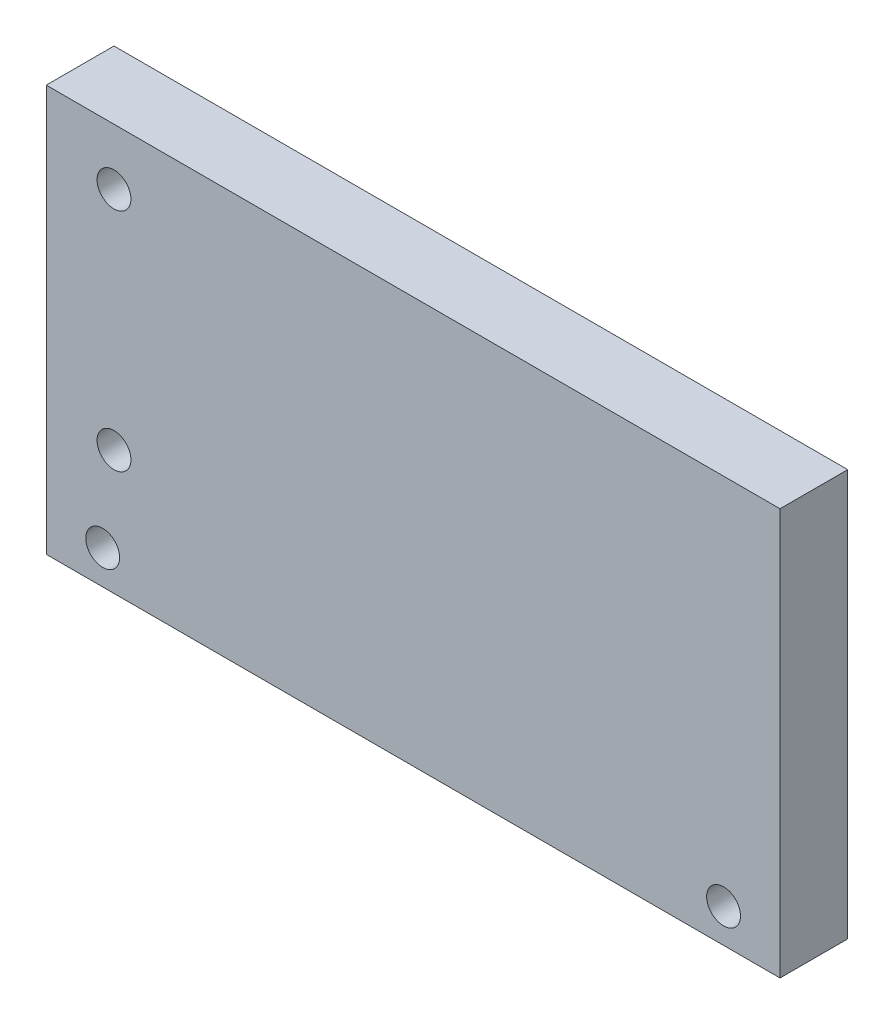
from build123d import *

# Parameters (mm, degrees)
ESQUISSE1_W             = 65
ESQUISSE1_H             = 36
ESQUISSE1_R             = 1.5
BOSS_EXTRU_1_DEPTH      = 6
ESQUISSE3_R             = 1.5
ENL_V_MAT_EXTRU_1_DEPTH = 10


with BuildPart() as part:
    # Esquisse1 → Boss.-Extru.1 (new body)
    with BuildSketch(Plane.XY):
        with Locations((-7.771220945, 18.631944444)):
            Rectangle(ESQUISSE1_W, ESQUISSE1_H)
        with Locations((-34.271220945, 31.631944444)):
            Circle(ESQUISSE1_R, mode=Mode.SUBTRACT)
        with Locations((-34.271220945, 11.631944444)):
            Circle(ESQUISSE1_R, mode=Mode.SUBTRACT)
    extrude(amount=BOSS_EXTRU_1_DEPTH)

    # Esquisse3 → Enlèv. mat.-Extru.1 (cut)
    with BuildSketch(Plane.XY.offset(6)):
        with Locations((-35.271220945, 3.631944444)):
            Circle(ESQUISSE3_R)
        with Locations((19.728779055, 3.631944444)):
            Circle(ESQUISSE3_R)
    extrude(amount=-ENL_V_MAT_EXTRU_1_DEPTH, mode=Mode.SUBTRACT)


solid = part.part
